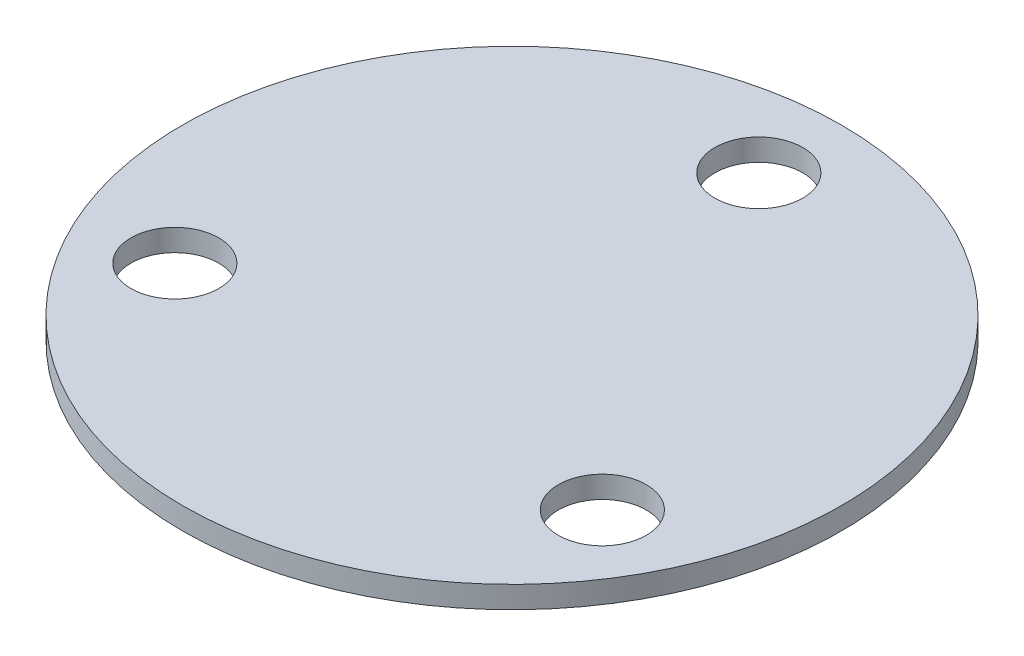
from build123d import *

# Parameters (mm, degrees)
SKETCH1_R           = 75
BOSS_EXTRUDE1_DEPTH = 5
SKETCH2_R           = 10
CUT_EXTRUDE1_DEPTH  = 5


with BuildPart() as part:
    # Sketch1 → Boss-Extrude1 (new body)
    with BuildSketch(Plane(origin=(0, 0, 0), x_dir=(1, 0, 0), z_dir=(0, 1, 0))):
        Circle(SKETCH1_R)
    extrude(amount=BOSS_EXTRUDE1_DEPTH)

    # Sketch2 → Cut-Extrude1 (cut)
    with BuildSketch(Plane(origin=(0, 5, 0), x_dir=(1, 0, 0), z_dir=(0, 1, 0))):
        with Locations((0, 56.168516558)):
            Circle(SKETCH2_R)
        with Locations((48.643362232, -28.084258279)):
            Circle(SKETCH2_R)
        with Locations((-48.643362232, -28.084258279)):
            Circle(SKETCH2_R)
    extrude(amount=-CUT_EXTRUDE1_DEPTH, mode=Mode.SUBTRACT)


solid = part.part
